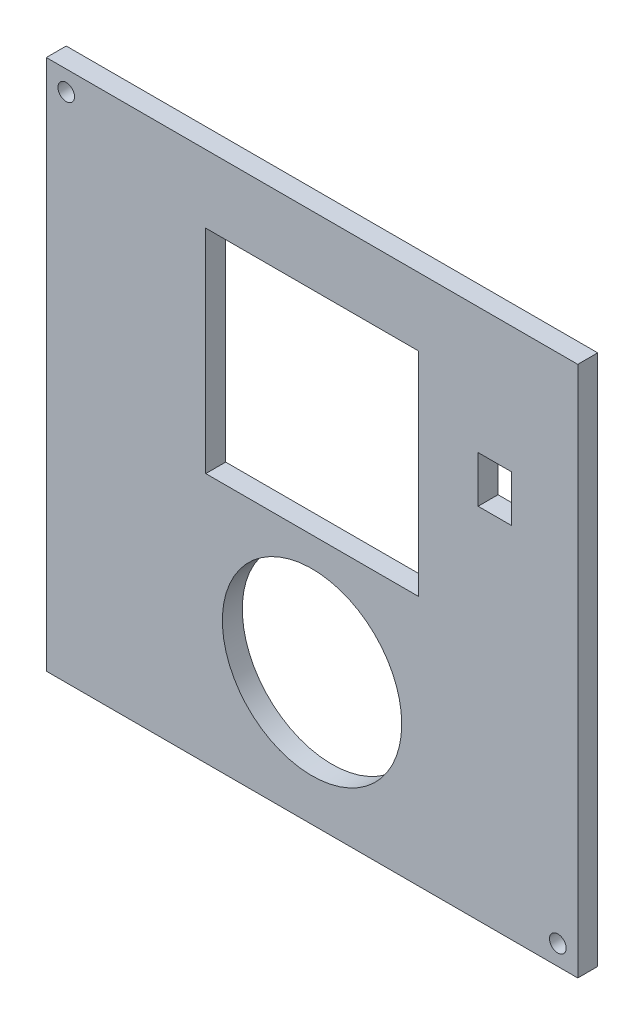
from build123d import *

# Parameters (mm, degrees)
SKETCH1_W           = 80
SKETCH1_H           = 80
BOSS_EXTRUDE1_DEPTH = 3
SKETCH2_R           = 1.25
CUT_EXTRUDE1_DEPTH  = 3
SKETCH3_R           = 1.25
CUT_EXTRUDE2_DEPTH  = 3
CUT_EXTRUDE3_DEPTH  = 3
SKETCH5_R           = 13.5
CUT_EXTRUDE4_DEPTH  = 3
CUT_EXTRUDE5_DEPTH  = 24


with BuildPart() as part:
    # Sketch1 → Boss-Extrude1 (new body)
    with BuildSketch(Plane.XY):
        with Locations((40, 40)):
            Rectangle(SKETCH1_W, SKETCH1_H)
    extrude(amount=BOSS_EXTRUDE1_DEPTH)

    # Sketch2 → Cut-Extrude1 (cut)
    with BuildSketch(Plane.XY.offset(3)):
        with Locations((3, 77)):
            Circle(SKETCH2_R)
    extrude(amount=-CUT_EXTRUDE1_DEPTH, mode=Mode.SUBTRACT)

    # Sketch3 → Cut-Extrude2 (cut)
    with BuildSketch(Plane.XY.offset(3)):
        with Locations((77, 3)):
            Circle(SKETCH3_R)
    extrude(amount=-CUT_EXTRUDE2_DEPTH, mode=Mode.SUBTRACT)

    # Sketch4 → Cut-Extrude3 (cut)
    with BuildSketch(Plane(origin=(0, 3.75760721, 3), x_dir=(1, 0, 0), z_dir=(0, 0, 1))):
        Polygon((40, 34), (56, 34), (56, 50), (56, 66), (40, 66), (24, 66), (24, 34), align=None)
    extrude(amount=-CUT_EXTRUDE3_DEPTH, mode=Mode.SUBTRACT)

    # Sketch5 → Cut-Extrude4 (cut)
    with BuildSketch(Plane(origin=(0, 0.849012918, 3), x_dir=(1, 0, 0), z_dir=(0, 0, 1))):
        with Locations((40, 19.003705046)):
            Circle(SKETCH5_R)
    extrude(amount=-CUT_EXTRUDE4_DEPTH, mode=Mode.SUBTRACT)

    # Sketch6 → Cut-Extrude5 (cut)
    with BuildSketch(Plane.XY.offset(3)):
        Polygon((70, 59), (70, 54), (65, 54), (65, 59), (65, 61), (70, 61), align=None)
    extrude(amount=-CUT_EXTRUDE5_DEPTH, mode=Mode.SUBTRACT)


solid = part.part
